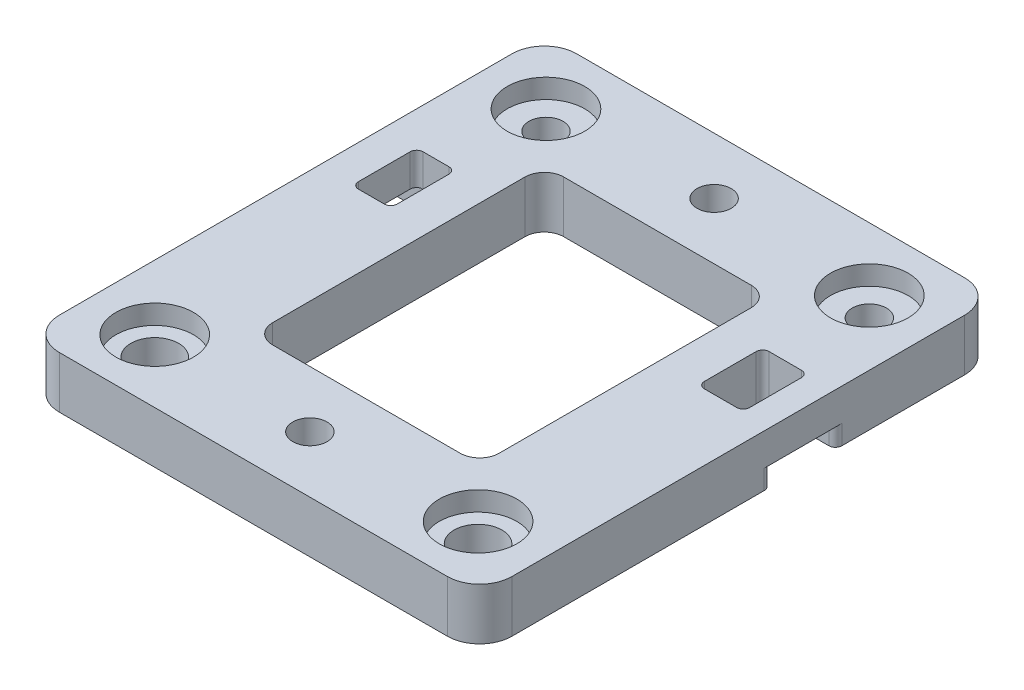
from build123d import *

# Parameters (mm, degrees)
CROQUIS1_R              = 6
CROQUIS1_R_2            = 2.65
SALIENTE_EXTRUIR1_DEPTH = 8
CROQUIS1_4_R            = 6
CROQUIS1_4_R_2          = 3.7
CROQUIS1_4_R_3          = 2.65
SALIENTE_EXTRUIR2_DEPTH = 5
CROQUIS1_6_R            = 3.7
CROQUIS1_6_R_2          = 2.65
CORTAR_EXTRUIR1_DEPTH   = 5
CORTAR_EXTRUIR2_DEPTH   = 3


with BuildPart() as part:
    # Croquis1 → Saliente-Extruir1 (new body)
    with BuildSketch(Plane(origin=(0, 0, 0), x_dir=(1, 0, 0), z_dir=(0, 1, 0))):
        with BuildLine():
            Line((-35, 35), (-35, -35))
            ThreePointArc((-35, -35), (-33.535533906, -38.535533906), (-30, -40))
            Line((-30, -40), (30, -40))
            ThreePointArc((30, -40), (33.535533906, -38.535533906), (35, -35))
            Line((35, -35), (35, 35))
            ThreePointArc((35, 35), (33.535533906, 38.535533906), (30, 40))
            Line((30, 40), (-30, 40))
            ThreePointArc((-30, 40), (-33.535533906, 38.535533906), (-35, 35))
        make_face()
        with Locations((-24.99964, -30.24738)):
            Circle(CROQUIS1_R, mode=Mode.SUBTRACT)
        with Locations((0, -31.2526)):
            Circle(CROQUIS1_R_2, mode=Mode.SUBTRACT)
        with Locations((24.99964, -30.24738)):
            Circle(CROQUIS1_R, mode=Mode.SUBTRACT)
        with BuildLine():
            ThreePointArc((-29.75, 14), (-29.457106781, 14.707106781), (-28.75, 15))
            Line((-28.75, 15), (-24.75, 15))
            ThreePointArc((-24.75, 15), (-24.042893219, 14.707106781), (-23.75, 14))
            Line((-23.75, 14), (-23.75, 6))
            ThreePointArc((-23.75, 6), (-24.042893219, 5.292893219), (-24.75, 5))
            Line((-24.75, 5), (-28.75, 5))
            ThreePointArc((-28.75, 5), (-29.457106781, 5.292893219), (-29.75, 6))
            Line((-29.75, 6), (-29.75, 14))
        make_face(mode=Mode.SUBTRACT)
        with Locations((-24.99964, 30.25392)):
            Circle(CROQUIS1_R, mode=Mode.SUBTRACT)
        with BuildLine():
            Line((14.5, -22.5), (-14.5, -22.5))
            ThreePointArc((-14.5, -22.5), (-16.621320344, -21.621320344), (-17.5, -19.5))
            Line((-17.5, -19.5), (-17.5, 19.5))
            ThreePointArc((-17.5, 19.5), (-16.621320344, 21.621320344), (-14.5, 22.5))
            Line((-14.5, 22.5), (14.5, 22.5))
            ThreePointArc((14.5, 22.5), (16.621320344, 21.621320344), (17.5, 19.5))
            Line((17.5, 19.5), (17.5, -19.5))
            ThreePointArc((17.5, -19.5), (16.621320344, -21.621320344), (14.5, -22.5))
        make_face(mode=Mode.SUBTRACT)
        with BuildLine():
            ThreePointArc((23.75, 14), (24.042893219, 14.707106781), (24.75, 15))
            Line((24.75, 15), (29.75, 15))
            ThreePointArc((29.75, 15), (30.457106781, 14.707106781), (30.75, 14))
            Line((30.75, 14), (30.75, 6))
            ThreePointArc((30.75, 6), (30.457106781, 5.292893219), (29.75, 5))
            Line((29.75, 5), (24.75, 5))
            ThreePointArc((24.75, 5), (24.042893219, 5.292893219), (23.75, 6))
            Line((23.75, 6), (23.75, 14))
        make_face(mode=Mode.SUBTRACT)
        with Locations((0, 31.2526)):
            Circle(CROQUIS1_R_2, mode=Mode.SUBTRACT)
        with Locations((24.99964, 30.25392)):
            Circle(CROQUIS1_R, mode=Mode.SUBTRACT)
    extrude(amount=SALIENTE_EXTRUIR1_DEPTH)

    # Croquis1_4 → Saliente-Extruir2 (add)
    # profile 1 of 4: a face of its own
    with BuildSketch(Plane(origin=(0, 0, 0), x_dir=(1, 0, 0), z_dir=(0, 1, 0))):
        with Locations((-24.99964, -30.24738)):
            Circle(CROQUIS1_4_R)
        with Locations((-24.99964, -30.24738)):
            Circle(CROQUIS1_4_R_2, mode=Mode.SUBTRACT)
    # profile 2 of 4: a face of its own
    with BuildSketch(Plane(origin=(0, 0, 0), x_dir=(1, 0, 0), z_dir=(0, 1, 0))):
        with Locations((-24.99964, 30.25392)):
            Circle(CROQUIS1_4_R)
        with Locations((-24.99964, 30.25392)):
            Circle(CROQUIS1_4_R_3, mode=Mode.SUBTRACT)
    # profile 3 of 4: a face of its own
    with BuildSketch(Plane(origin=(0, 0, 0), x_dir=(1, 0, 0), z_dir=(0, 1, 0))):
        with Locations((24.99964, -30.24738)):
            Circle(CROQUIS1_4_R)
    # profile 4 of 4: a face of its own
    with BuildSketch(Plane(origin=(0, 0, 0), x_dir=(1, 0, 0), z_dir=(0, 1, 0))):
        with Locations((24.99964, 30.25392)):
            Circle(CROQUIS1_4_R)
    extrude(amount=SALIENTE_EXTRUIR2_DEPTH)

    # Croquis1_6 → Cortar-Extruir1 (cut)
    with BuildSketch(Plane(origin=(0, 0, 0), x_dir=(1, 0, 0), z_dir=(0, 1, 0))):
        with Locations((24.99964, -30.24738)):
            Circle(CROQUIS1_6_R)
        with Locations((24.99964, 30.25392)):
            Circle(CROQUIS1_6_R_2)
    extrude(amount=CORTAR_EXTRUIR1_DEPTH, mode=Mode.SUBTRACT)

    # Croquis3 → Cortar-Extruir2 (cut)
    with BuildSketch(Plane.XZ):
        with BuildLine():
            Line((-35, -4), (-35, -16))
            ThreePointArc((-35, -16), (-34.707106781, -15.292893219), (-34, -15))
            Line((-34, -15), (-28.75, -15))
            Line((-28.75, -15), (-28.75, -5))
            Line((-28.75, -5), (-34, -5))
            ThreePointArc((-34, -5), (-34.707106781, -4.707106781), (-35, -4))
        make_face()
        with BuildLine():
            Line((35, -4), (35, -16))
            ThreePointArc((35, -16), (34.707106781, -15.292893219), (34, -15))
            Line((34, -15), (29.75, -15))
            Line((29.75, -15), (29.75, -5))
            Line((29.75, -5), (34, -5))
            ThreePointArc((34, -5), (34.707106781, -4.707106781), (35, -4))
        make_face()
    extrude(amount=-CORTAR_EXTRUIR2_DEPTH, mode=Mode.SUBTRACT)


solid = part.part
